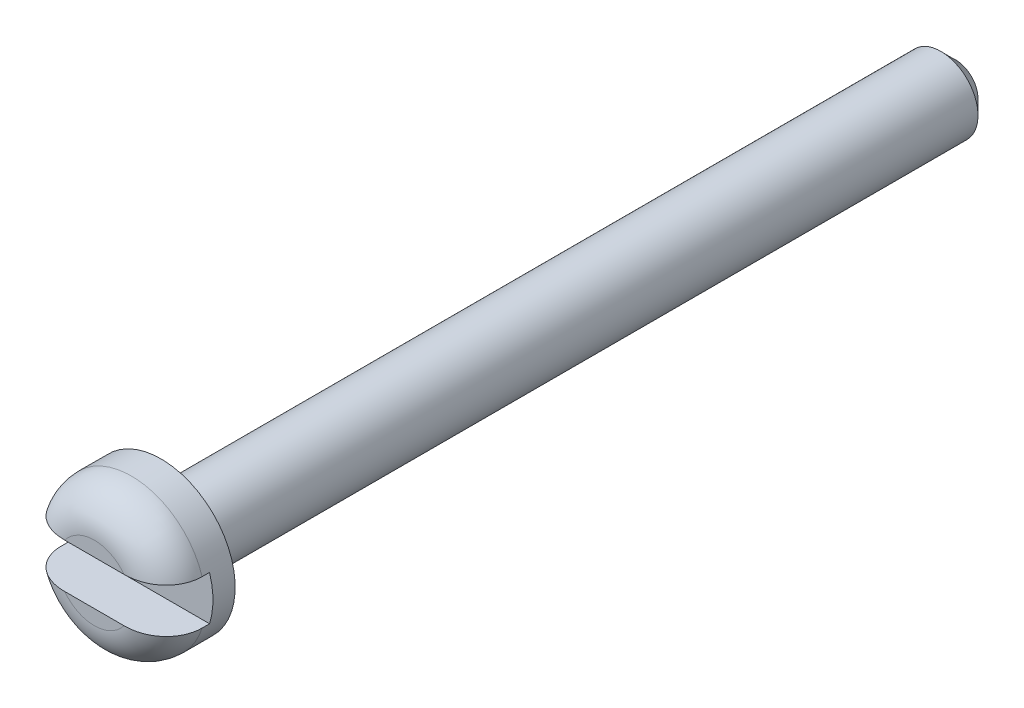
from build123d import *

# Parameters (mm, degrees)
SKETCH_2_W               = 1.2
SKETCH_2_H               = 1.2
CUT_EXTRUDE_1_DEPTH      = 3
CUT_EXTRUDE_1_DEPTH_BACK = 3
CHAMFER_1_SIZE           = 0.4
FILLET_1_R               = 1
FILLET_2_R               = 0.4


with BuildPart() as part:
    # Эскиз1 → Повернуть1 (revolve)
    with BuildSketch(Plane(origin=(0, 0, 0), x_dir=(1, 0, 0), z_dir=(0, 1, 0))):
        Polygon((0, 0), (-2, 0), (-2, 1.8), (-1, 1.8), (-1, 23.25), (0, 23.25), align=None)
    revolve(axis=Axis((0, 0, -23.25), (0, 0, 1)))

    # Эскиз2 → Вырез-Вытянуть1 (cut, two sides)
    with BuildSketch(Plane(origin=(0, 0, 0), x_dir=(0, 0, -1), z_dir=(1, 0, 0))) as cut_extrude_1_sk:
        with Locations((0.6, 0)):
            Rectangle(SKETCH_2_W, SKETCH_2_H)
    extrude(amount=CUT_EXTRUDE_1_DEPTH, mode=Mode.SUBTRACT)
    extrude(cut_extrude_1_sk.sketch, amount=-CUT_EXTRUDE_1_DEPTH_BACK, mode=Mode.SUBTRACT)

    # Фаска1
    chamfer_1_edges = [part.edges().sort_by_distance(p)[0] for p in [
        (1, 0, -23.25),
    ]]
    chamfer(chamfer_1_edges, length=CHAMFER_1_SIZE)

    # Скругление1
    fillet_1_edges = [part.edges().sort_by_distance(p)[0] for p in [
        (0, 2, 0),
        (0, -2, 0),
    ]]
    fillet(fillet_1_edges, radius=FILLET_1_R)

    # Скругление2
    fillet_2_edges = [part.edges().sort_by_distance(p)[0] for p in [
        (1, 0, -1.8),
    ]]
    fillet(fillet_2_edges, radius=FILLET_2_R)


solid = part.part
